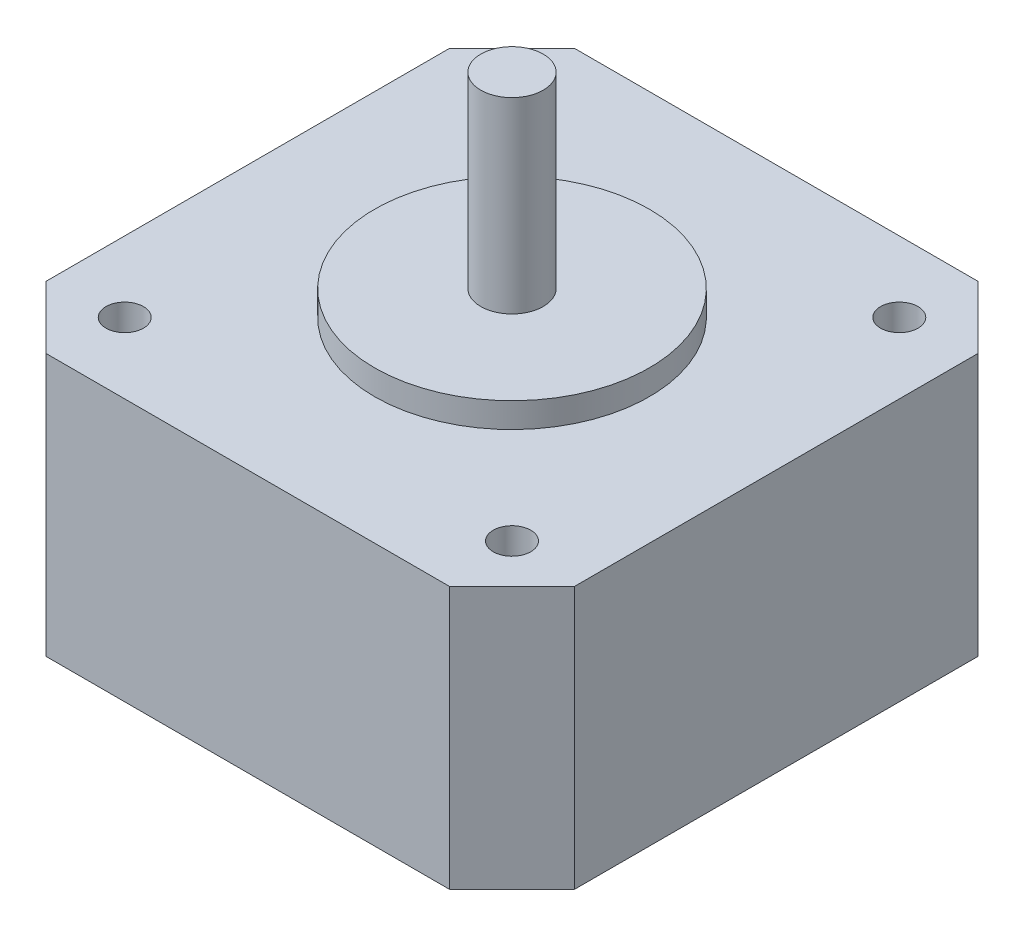
from build123d import *

# Parameters (mm, degrees)
SKETCH1_W           = 42.3
SKETCH1_H           = 42.3
BOSS_EXTRUDE1_DEPTH = 21
CHAMFER1_SIZE       = 5
SKETCH2_R           = 1.5
CUT_EXTRUDE1_DEPTH  = 3
SKETCH3_R           = 11
BOSS_EXTRUDE2_DEPTH = 2
SKETCH4_R           = 2.5
BOSS_EXTRUDE3_DEPTH = 15


with BuildPart() as part:
    # Sketch1 → Boss-Extrude1 (new body)
    with BuildSketch(Plane(origin=(0, 0, 0), x_dir=(1, 0, 0), z_dir=(0, 1, 0))):
        Rectangle(SKETCH1_W, SKETCH1_H)
    extrude(amount=BOSS_EXTRUDE1_DEPTH)

    # Chamfer1
    chamfer1_edges = [part.edges().sort_by_distance(p)[0] for p in [
        (21.15, 10.5, 21.15),
        (-21.15, 10.5, 21.15),
        (-21.15, 10.5, -21.15),
        (21.15, 10.5, -21.15),
    ]]
    chamfer(chamfer1_edges, length=CHAMFER1_SIZE)

    # Sketch2 → Cut-Extrude1 (cut)
    with BuildSketch(Plane(origin=(0, 21, 0), x_dir=(1, 0, 0), z_dir=(0, 1, 0))):
        with Locations((15.5, -15.5)):
            Circle(SKETCH2_R)
        with Locations((15.5, 15.5)):
            Circle(SKETCH2_R)
        with Locations((-15.5, 15.5)):
            Circle(SKETCH2_R)
        with Locations((-15.5, -15.5)):
            Circle(SKETCH2_R)
    extrude(amount=-CUT_EXTRUDE1_DEPTH, mode=Mode.SUBTRACT)

    # Sketch3 → Boss-Extrude2 (add)
    with BuildSketch(Plane(origin=(0, 21, 0), x_dir=(1, 0, 0), z_dir=(0, 1, 0))):
        Circle(SKETCH3_R)
    extrude(amount=BOSS_EXTRUDE2_DEPTH)

    # Sketch4 → Boss-Extrude3 (add)
    with BuildSketch(Plane(origin=(0, 23, 0), x_dir=(1, 0, 0), z_dir=(0, 1, 0))):
        Circle(SKETCH4_R)
    extrude(amount=BOSS_EXTRUDE3_DEPTH)


solid = part.part
